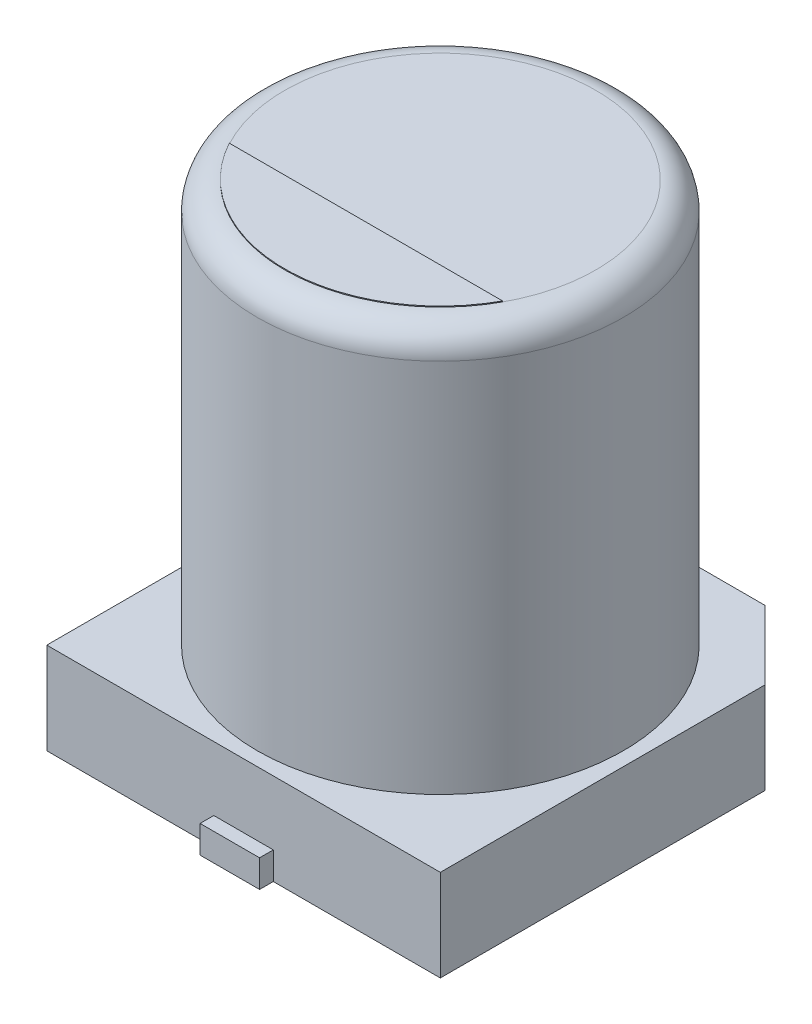
from build123d import *

# Parameters (mm, degrees)
BOSS_EXTRUDE1_DEPTH = 1
SKETCH3_R           = 2
BOSS_EXTRUDE2_DEPTH = 5.4
FILLET1_R           = 0.3
SKETCH4_W           = 0.65
SKETCH4_H           = 1.8
BOSS_EXTRUDE3_DEPTH = 0.3
BOSS_EXTRUDE4_DEPTH = 0.01


with BuildPart() as part:
    # Sketch2 → Boss-Extrude1 (new body)
    with BuildSketch(Plane(origin=(0, 0, 0), x_dir=(1, 0, 0), z_dir=(0, 1, 0))):
        Polygon((2.15, -2.15), (-2.15, -2.15), (-2.15, 1.4), (-1.4, 2.15), (1.4, 2.15), (2.15, 1.4), align=None)
    extrude(amount=BOSS_EXTRUDE1_DEPTH)

    # Sketch3 → Boss-Extrude2 (add)
    with BuildSketch(Plane(origin=(0, 0, 0), x_dir=(1, 0, 0), z_dir=(0, 1, 0))):
        Circle(SKETCH3_R)
    extrude(amount=BOSS_EXTRUDE2_DEPTH)

    # Fillet1
    fillet1_edges = [part.edges().sort_by_distance(p)[0] for p in [
        (-2, 5.4, 0),
    ]]
    fillet(fillet1_edges, radius=FILLET1_R)

    # Sketch4 → Boss-Extrude3 (add)
    with BuildSketch(Plane(origin=(0, 0, 0), x_dir=(1, 0, 0), z_dir=(0, 1, 0))):
        with Locations((0, 1.4)):
            Rectangle(SKETCH4_W, SKETCH4_H)
        with Locations((0, -1.4)):
            Rectangle(SKETCH4_W, SKETCH4_H)
    extrude(amount=BOSS_EXTRUDE3_DEPTH)

    # Sketch5 → Boss-Extrude4 (add)
    with BuildSketch(Plane(origin=(0, 5.4, 0), x_dir=(1, 0, 0), z_dir=(0, 1, 0))):
        with BuildLine():
            Line((1.493037561, -0.812919948), (-1.493037561, -0.812919948))
            ThreePointArc((-1.493037561, -0.812919948), (0, -1.7), (1.493037561, -0.812919948))
        make_face()
    extrude(amount=BOSS_EXTRUDE4_DEPTH)


solid = part.part
